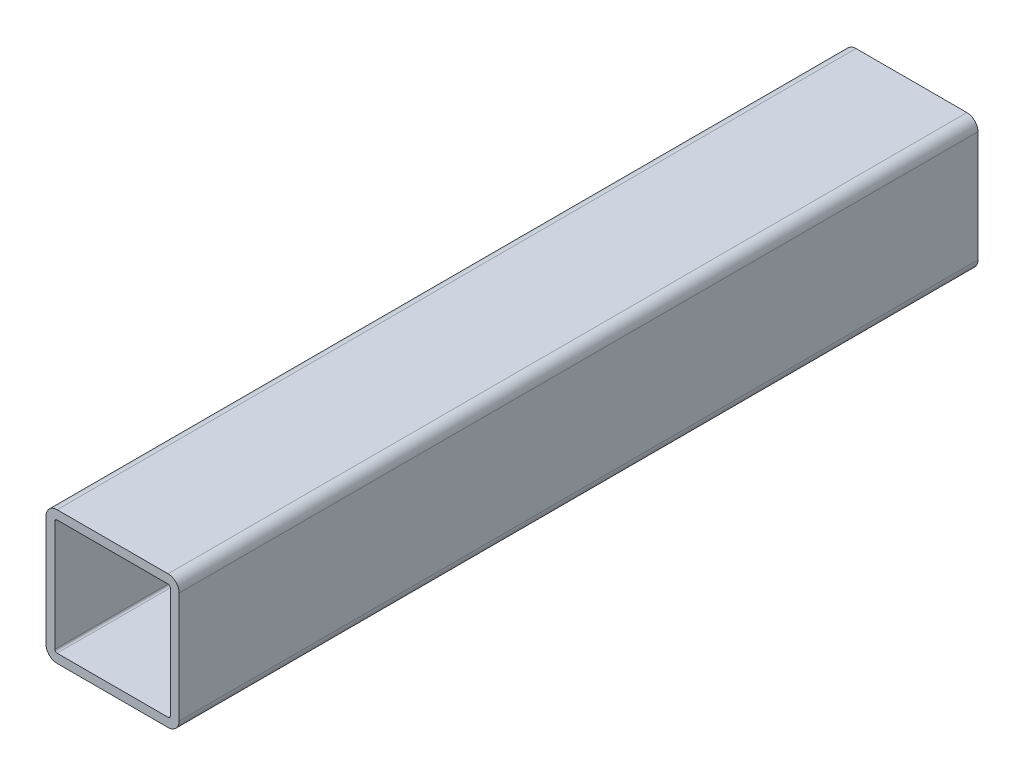
from build123d import *

# Parameters (mm, degrees)
EXTRUDE_THIN1_DEPTH = 114.3


with BuildPart() as part:
    # Sketch1 → Extrude-Thin1 (new body, symmetric)
    with BuildSketch(Plane.XY):
        with BuildLine():
            Line((-15.875, 19.05), (15.875, 19.05))
            ThreePointArc((15.875, 19.05), (18.12006403, 18.12006403), (19.05, 15.875))
            Line((19.05, 15.875), (19.05, -15.875))
            ThreePointArc((19.05, -15.875), (18.12006403, -18.12006403), (15.875, -19.05))
            Line((15.875, -19.05), (-15.875, -19.05))
            ThreePointArc((-15.875, -19.05), (-18.12006403, -18.12006403), (-19.05, -15.875))
            Line((-19.05, -15.875), (-19.05, 15.875))
            ThreePointArc((-19.05, 15.875), (-18.12006403, 18.12006403), (-15.875, 19.05))
        make_face()
        with BuildLine():
            Line((-15.875, 16.51), (15.875, 16.51))
            ThreePointArc((15.875, 16.51), (16.324012806, 16.324012806), (16.51, 15.875))
            Line((16.51, 15.875), (16.51, -15.875))
            ThreePointArc((16.51, -15.875), (16.324012806, -16.324012806), (15.875, -16.51))
            Line((15.875, -16.51), (-15.875, -16.51))
            ThreePointArc((-15.875, -16.51), (-16.324012806, -16.324012806), (-16.51, -15.875))
            Line((-16.51, -15.875), (-16.51, 15.875))
            ThreePointArc((-16.51, 15.875), (-16.324012806, 16.324012806), (-15.875, 16.51))
        make_face(mode=Mode.SUBTRACT)
    extrude(amount=EXTRUDE_THIN1_DEPTH, both=True)


solid = part.part
